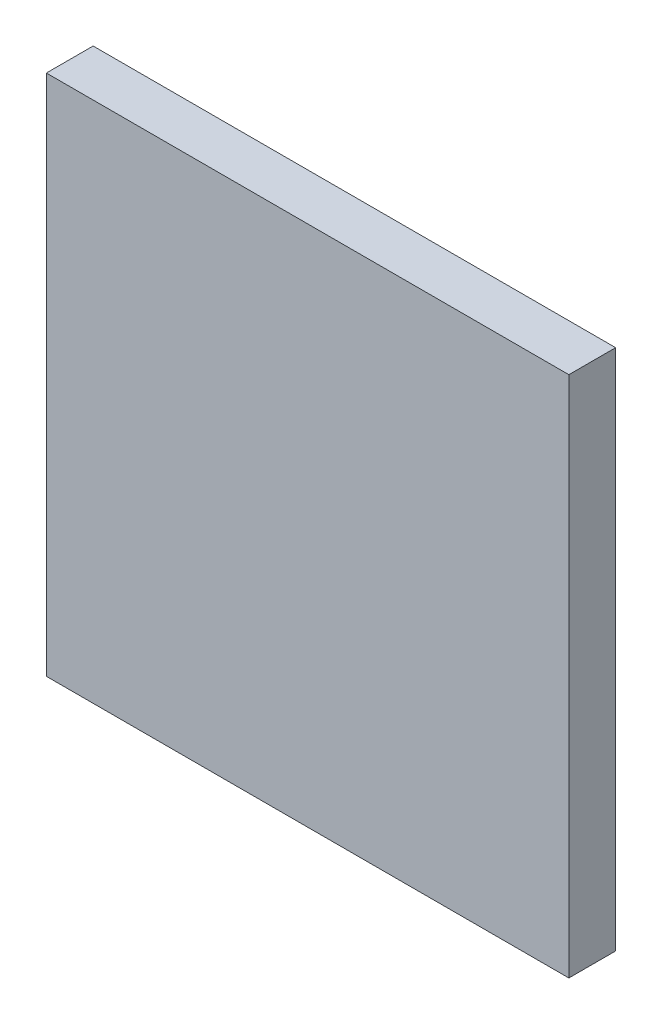
from build123d import *

# Parameters (mm, degrees)
SKETCH1_W           = 17.7292
SKETCH1_H           = 17.7292
BOSS_EXTRUDE1_DEPTH = 1.5875


with BuildPart() as part:
    # Sketch1 → Boss-Extrude1 (new body)
    with BuildSketch(Plane.XY):
        with Locations((-88.773, 65.024)):
            Rectangle(SKETCH1_W, SKETCH1_H)
    extrude(amount=BOSS_EXTRUDE1_DEPTH)


solid = part.part
